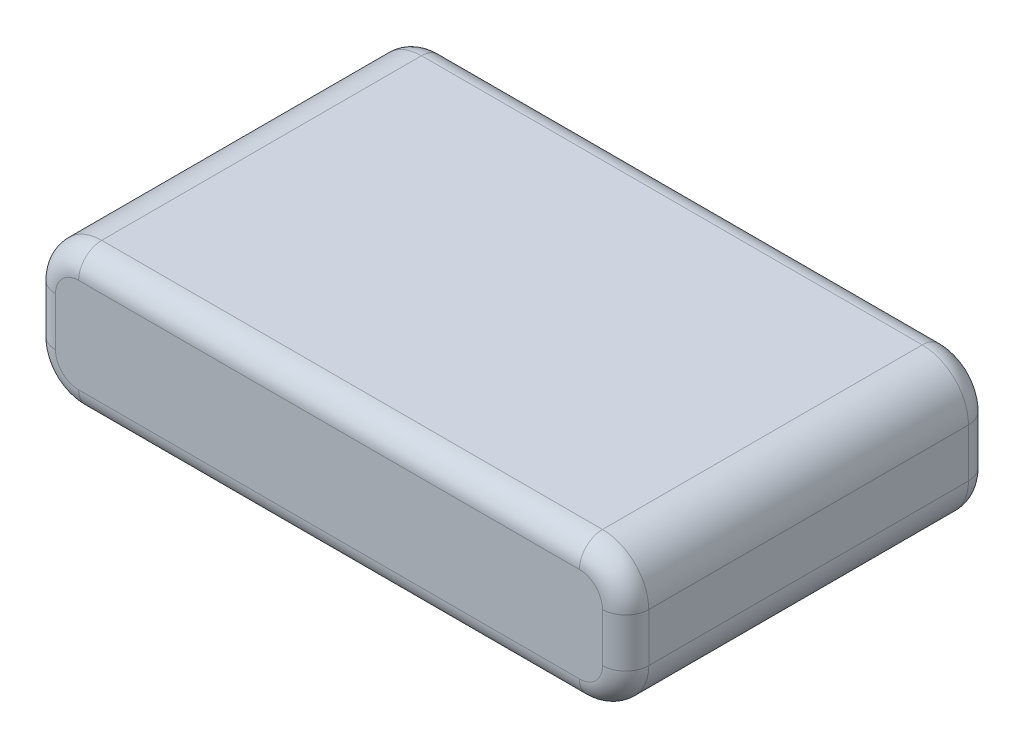
from build123d import *

# Parameters (mm, degrees)
SKETCH1_W           = 38.5
SKETCH1_H           = 23.75
BOSS_EXTRUDE1_DEPTH = 9.15
FILLET1_R           = 3
FILLET2_R           = 1.5


with BuildPart() as part:
    # Sketch1 → Boss-Extrude1 (new body)
    with BuildSketch(Plane(origin=(0, 0, 0), x_dir=(1, 0, 0), z_dir=(0, 1, 0))):
        Rectangle(SKETCH1_W, SKETCH1_H)
    extrude(amount=BOSS_EXTRUDE1_DEPTH)

    # Fillet1
    fillet1_edges = [part.edges().sort_by_distance(p)[0] for p in [
        (-19.25, 9.15, 0),
        (19.25, 9.15, 0),
        (-19.25, 0, 0),
        (19.25, 0, 0),
    ]]
    fillet(fillet1_edges, radius=FILLET1_R)

    # Fillet2
    fillet2_edges = [part.edges().sort_by_distance(p)[0] for p in [
        (-19.25, 4.575, 11.875),
        (-19.25, 4.575, -11.875),
        (0, 0, 11.875),
        (19.25, 4.575, 11.875),
        (0, 9.15, 11.875),
        (18.371320344, 8.271320344, 11.875),
        (18.371320344, 0.878679656, 11.875),
        (-18.371320344, 8.271320344, 11.875),
        (-18.371320344, 0.878679656, 11.875),
        (0, 0, -11.875),
        (0, 9.15, -11.875),
        (19.25, 4.575, -11.875),
        (18.371320344, 8.271320344, -11.875),
        (18.371320344, 0.878679656, -11.875),
        (-18.371320344, 8.271320344, -11.875),
        (-18.371320344, 0.878679656, -11.875),
    ]]
    fillet(fillet2_edges, radius=FILLET2_R)


solid = part.part
